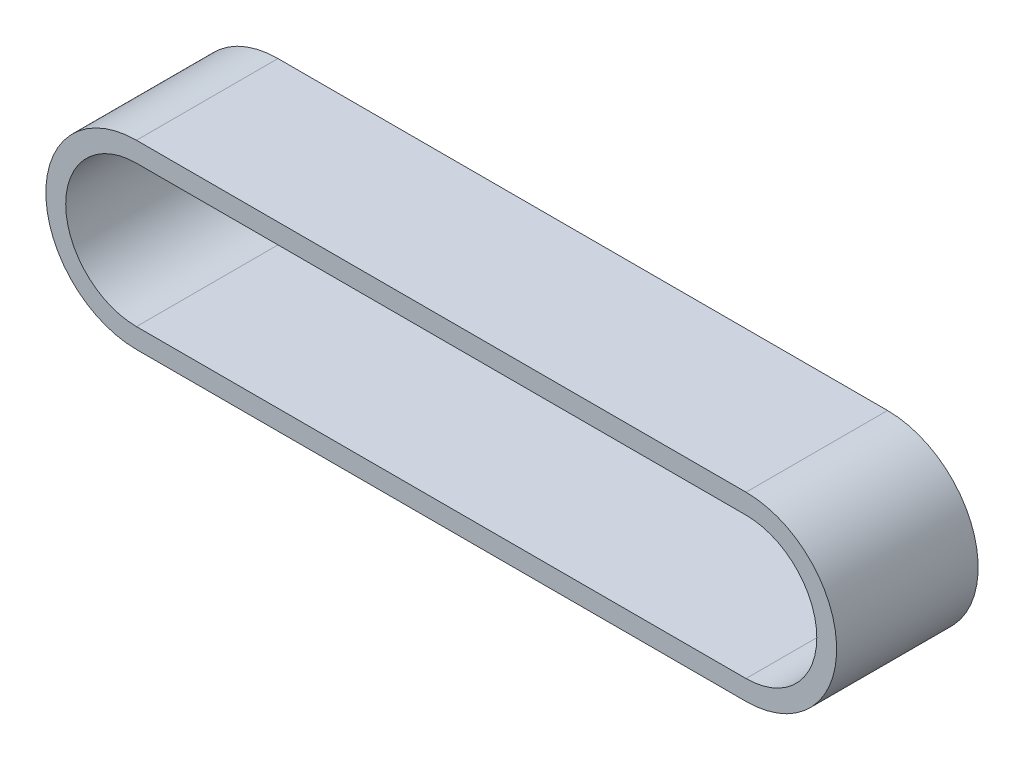
from build123d import *

# Parameters (mm, degrees)
RESSALTO_EXTRUS_O1_DEPTH = 25


with BuildPart() as part:
    # Esboço1 → Ressalto-extrusão1 (new body)
    with BuildSketch(Plane.XY):
        with BuildLine():
            Line((0, 3.509023642), (107.682833186, 3.509023642))
            ThreePointArc((107.682833186, 3.509023642), (123.691856828, -12.5), (107.682833186, -28.509023642))
            Line((107.682833186, -28.509023642), (0, -28.509023642))
            ThreePointArc((0, -28.509023642), (-16.009023642, -12.5), (0, 3.509023642))
        make_face()
        with BuildLine():
            Line((0, 0), (107.682833186, 0))
            ThreePointArc((107.682833186, 0), (120.182833186, -12.5), (107.682833186, -25))
            Line((107.682833186, -25), (0, -25))
            ThreePointArc((0, -25), (-12.5, -12.5), (0, 0))
        make_face(mode=Mode.SUBTRACT)
    extrude(amount=RESSALTO_EXTRUS_O1_DEPTH)


solid = part.part
